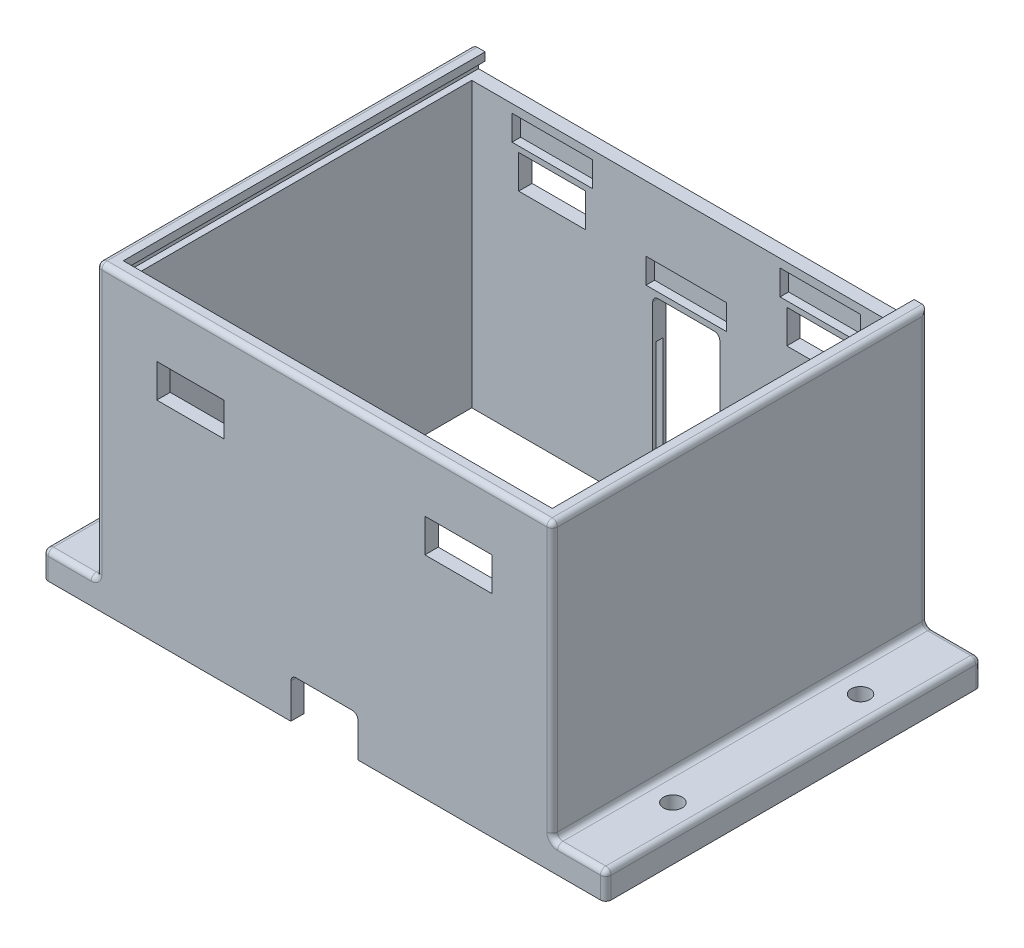
from build123d import *

# Parameters (mm, degrees)
BOSS_EXTRUDE1_DEPTH      = 170
SKETCH7_W                = 5
SKETCH7_H                = 112.5
BOSS_EXTRUDE2_DEPTH      = 130
SKETCH9_W                = 160
SKETCH9_H                = 130
CUT_EXTRUDE2_DEPTH       = 60
SKETCH10_W               = 165
SKETCH10_H               = 3.7
CUT_EXTRUDE3_DEPTH       = 137.5
SKETCH13_W               = 160
SKETCH13_H               = 6
CUT_EXTRUDE4_DEPTH       = 5
SKETCH15_W               = 20
SKETCH15_H               = 10
BOSS_EXTRUDE3_DEPTH      = 70
SKETCH16_W               = 25
SKETCH16_H               = 12.5
CUT_EXTRUDE5_DEPTH       = 5
M6_CLEARANCE_HOLE1_D     = 7
M6_CLEARANCE_HOLE1_DEPTH = 10
SKETCH26_W               = 30
SKETCH26_H               = 9.35
CUT_EXTRUDE6_DEPTH       = 68.2
SKETCH27_W               = 30
SKETCH27_H               = 9.35
CUT_EXTRUDE8_DEPTH       = 68.2
CUT_EXTRUDE10_DEPTH      = 5
CUT_EXTRUDE11_DEPTH      = 5
SKETCH30_W               = 30
SKETCH30_H               = 9.35
CUT_EXTRUDE12_DEPTH      = 68.2
CUT_EXTRUDE14_DEPTH      = 54.5
FILLET1_R                = 2


with BuildPart() as part:
    # Sketch1 → Boss-Extrude1 (new body)
    with BuildSketch(Plane(origin=(0, 0, 0), x_dir=(0, 0, -1), z_dir=(1, 0, 0))):
        Polygon((90, 112.5), (90, 0), (85, 0), (85, 107.5), (-45, 107.5), (-45, 0), (-50, 0), (-50, 112.5), align=None)
    extrude(amount=BOSS_EXTRUDE1_DEPTH)

    # Sketch7 → Boss-Extrude2 (add)
    with BuildSketch(Plane(origin=(0, 0, 45), x_dir=(-1, 0, 0), z_dir=(0, 0, -1))):
        with Locations((-167.5, 56.25)):
            Rectangle(SKETCH7_W, SKETCH7_H)
        with Locations((-2.5, 56.25)):
            Rectangle(SKETCH7_W, SKETCH7_H)
    extrude(amount=BOSS_EXTRUDE2_DEPTH)

    # Sketch9 → Cut-Extrude2 (cut)
    with BuildSketch(Plane(origin=(0, 122.5, 0), x_dir=(1, 0, 0), z_dir=(0, 1, 0))):
        with Locations((85, 20)):
            Rectangle(SKETCH9_W, SKETCH9_H)
    extrude(amount=-CUT_EXTRUDE2_DEPTH, mode=Mode.SUBTRACT)

    # Sketch10 → Cut-Extrude3 (cut)
    with BuildSketch(Plane(origin=(80, 0, -90), x_dir=(1, 0, 0), z_dir=(0, 0, 1))):
        with Locations((5, 107.65)):
            Rectangle(SKETCH10_W, SKETCH10_H)
    extrude(amount=CUT_EXTRUDE3_DEPTH, mode=Mode.SUBTRACT)

    # Sketch13 → Cut-Extrude4 (cut)
    with BuildSketch(Plane(origin=(80, 0, -90), x_dir=(1, 0, 0), z_dir=(0, 0, 1))):
        with Locations((5, 109.5)):
            Rectangle(SKETCH13_W, SKETCH13_H)
    extrude(amount=CUT_EXTRUDE4_DEPTH, mode=Mode.SUBTRACT)

    # Sketch15 → Boss-Extrude3 (add, symmetric)
    with BuildSketch(Plane.XY.offset(-20)):
        with Locations((-10, 5)):
            Rectangle(SKETCH15_W, SKETCH15_H)
        with Locations((180, 5)):
            Rectangle(SKETCH15_W, SKETCH15_H)
    extrude(amount=BOSS_EXTRUDE3_DEPTH, both=True)

    # Sketch16 → Cut-Extrude5 (cut)
    with BuildSketch(Plane.XY.offset(50)):
        with Locations((35, 85)):
            Rectangle(SKETCH16_W, SKETCH16_H)
        with Locations((135, 85)):
            Rectangle(SKETCH16_W, SKETCH16_H)
    cut_extrude5 = extrude(amount=-CUT_EXTRUDE5_DEPTH, mode=Mode.SUBTRACT)

    # M6 Clearance Hole1
    with Locations(Plane(origin=(0, 10, 0), x_dir=(1, 0, 0), z_dir=(0, 1, 0))):
        with Locations((-10, -15), (-10, 55), (180, 55), (180, -15)):
            Hole(M6_CLEARANCE_HOLE1_D / 2, depth=M6_CLEARANCE_HOLE1_DEPTH)

    # Mirror2: Cut-Extrude5 across plane
    add(cut_extrude5.mirror(Plane.XY.offset(-20)), mode=Mode.SUBTRACT)

    # Sketch26 → Cut-Extrude6 (cut, symmetric)
    with BuildSketch(Plane.XY.offset(-20)):
        with Locations((135, 98)):
            Rectangle(SKETCH26_W, SKETCH26_H)
        with Locations((35, 98)):
            Rectangle(SKETCH26_W, SKETCH26_H)
    extrude(amount=CUT_EXTRUDE6_DEPTH, both=True, mode=Mode.SUBTRACT)

    # Sketch27 → Cut-Extrude8 (cut)
    with BuildSketch(Plane.XY.offset(-20)):
        with Locations((85, 21.8)):
            Rectangle(SKETCH27_W, SKETCH27_H)
    extrude(amount=CUT_EXTRUDE8_DEPTH, mode=Mode.SUBTRACT)

    # Sketch28 → Cut-Extrude10 (cut)
    with BuildSketch(Plane(origin=(0, 0, 50), x_dir=(-1, 0, 0), z_dir=(0, 0, -1))):
        with BuildLine():
            Line((-72.5, 0), (-72.5, 13))
            ThreePointArc((-72.5, 13), (-73.085786438, 14.414213562), (-74.5, 15))
            Line((-74.5, 15), (-95.5, 15))
            ThreePointArc((-95.5, 15), (-96.914213562, 14.414213562), (-97.5, 13))
            Line((-97.5, 13), (-97.5, 0))
            Line((-97.5, 0), (-72.5, 0))
        make_face()
    extrude(amount=CUT_EXTRUDE10_DEPTH, mode=Mode.SUBTRACT)

    # Sketch29 → Cut-Extrude11 (cut)
    with BuildSketch(Plane.XY.offset(-90)):
        with BuildLine():
            Line((95.5, 52.5), (74.5, 52.5))
            ThreePointArc((74.5, 52.5), (73.085786438, 53.085786438), (72.5, 54.5))
            Line((72.5, 54.5), (72.5, 68))
            ThreePointArc((72.5, 68), (73.085786438, 69.414213562), (74.5, 70))
            Line((74.5, 70), (95.5, 70))
            ThreePointArc((95.5, 70), (96.914213562, 69.414213562), (97.5, 68))
            Line((97.5, 68), (97.5, 54.5))
            ThreePointArc((97.5, 54.5), (96.914213562, 53.085786438), (95.5, 52.5))
        make_face()
    extrude(amount=CUT_EXTRUDE11_DEPTH, mode=Mode.SUBTRACT)

    # Sketch30 → Cut-Extrude12 (cut)
    with BuildSketch(Plane.XY.offset(-20)):
        with Locations((85, 76.8)):
            Rectangle(SKETCH30_W, SKETCH30_H)
    extrude(amount=-CUT_EXTRUDE12_DEPTH, mode=Mode.SUBTRACT)

    # Sketch31 → Cut-Extrude14 (cut)
    with BuildSketch(Plane(origin=(0, 0, 0), x_dir=(1, 0, 0), z_dir=(0, 1, 0))):
        Polygon((97.5, 86.25), (100.5, 86.25), (100.5, 88.75), (97.5, 88.75), (97.5, 90), (72.5, 90), (72.5, 88.75), (69.5, 88.75), (69.5, 86.25), (72.5, 86.25), (72.5, 85), (97.5, 85), align=None)
    extrude(amount=CUT_EXTRUDE14_DEPTH, mode=Mode.SUBTRACT)

    # Fillet1
    fillet1_edges = [part.edges().sort_by_distance(p)[0] for p in [
        (0, 61.25, 50),
        (0, 112.5, -20),
        (0, 61.25, -90),
        (-10, 10, -90),
        (0, 10, -20),
        (-20, 5, -90),
        (-20, 10, -20),
        (-10, 10, 50),
        (-20, 5, 50),
        (190, 5, -90),
        (180, 10, -90),
        (190, 10, -20),
        (170, 10, -20),
        (190, 5, 50),
        (180, 10, 50),
        (85, 112.5, 50),
        (170, 61.25, -90),
        (170, 112.5, -20),
        (170, 61.25, 50),
    ]]
    fillet(fillet1_edges, radius=FILLET1_R)


solid = part.part
